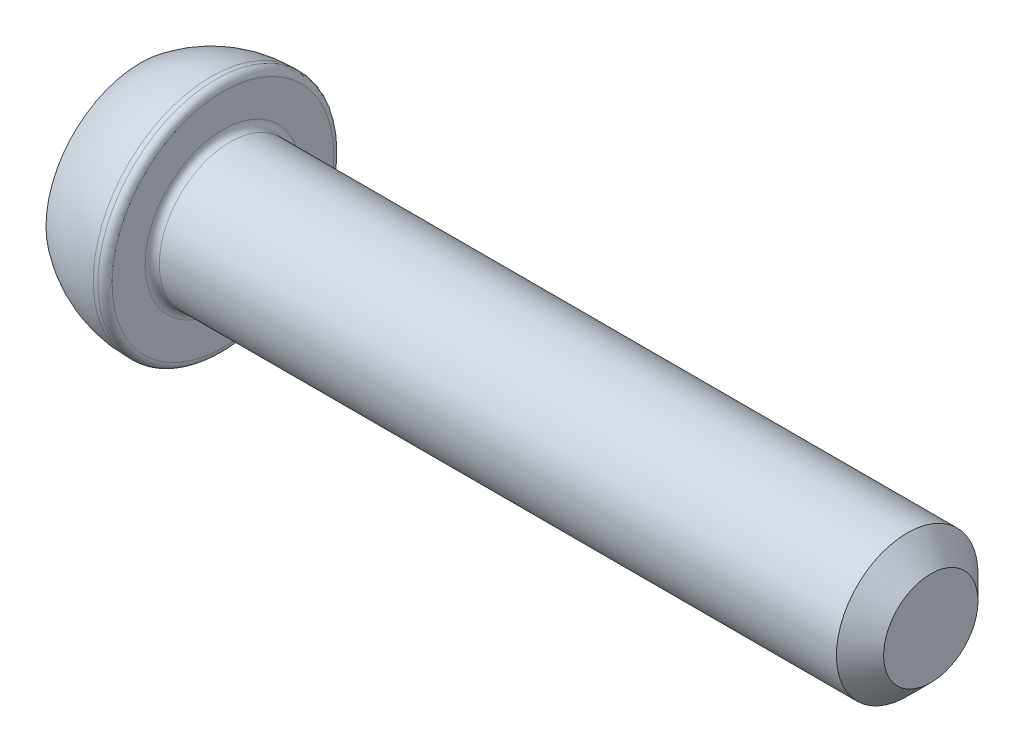
from build123d import *

# Parameters (mm, degrees)
CUT_EXTRUDE_1_DEPTH = 2
FILLET_1_R          = 0.3
CHAMFER_1_SIZE      = 1


with BuildPart() as part:
    # Эскиз1 → Повернуть1 (revolve)
    with BuildSketch(Plane.XY):
        with BuildLine():
            Line((0, 0), (0, 4))
            ThreePointArc((0, 4), (1.41886117, 4.74341649), (3, 5))
            Line((3, 5), (3.5, 5))
            Line((3.5, 5), (3.5, 3))
            Line((3.5, 3), (33.5, 3))
            Line((33.5, 3), (33.5, 0))
            Line((33.5, 0), (0, 0))
        make_face()
    revolve(axis=Axis((33.5, 0, 0), (-1, 0, 0)))

    # Эскиз2 → Вырез-Вытянуть1 (cut)
    with BuildSketch(Plane.ZY):
        Polygon((1.154700538, 2), (-1.154700538, 2), (-2.309401077, 0), (-1.154700538, -2), (1.154700538, -2), (2.309401077, 0), align=None)
    extrude(amount=-CUT_EXTRUDE_1_DEPTH, mode=Mode.SUBTRACT)

    # Скругление1
    fillet_1_edges = [part.edges().sort_by_distance(p)[0] for p in [
        (3.5, -3, 0),
        (3.5, -5, 0),
    ]]
    fillet(fillet_1_edges, radius=FILLET_1_R)

    # Фаска1
    chamfer_1_edges = [part.edges().sort_by_distance(p)[0] for p in [
        (33.5, -3, 0),
    ]]
    chamfer(chamfer_1_edges, length=CHAMFER_1_SIZE)


solid = part.part
